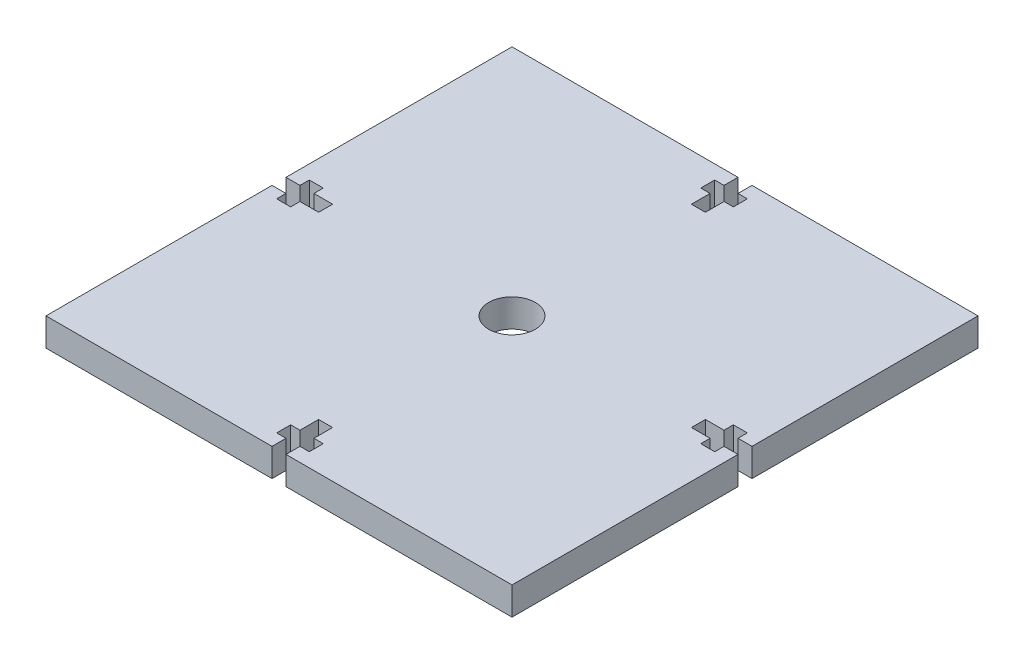
from build123d import *

# Parameters (mm, degrees)
SKETCH1_W           = 100
SKETCH1_H           = 100
BOSS_EXTRUDE1_DEPTH = 6
CUT_EXTRUDE1_DEPTH  = 142.548578234
SKETCH3_R           = 5
CUT_EXTRUDE2_DEPTH  = 10
CUT_EXTRUDE6_DEPTH  = 142.548578234


with BuildPart() as part:
    # Sketch1 → Boss-Extrude1 (new body)
    with BuildSketch(Plane(origin=(0, 0, 0), x_dir=(1, 0, 0), z_dir=(0, 1, 0))):
        with Locations((50, -50)):
            Rectangle(SKETCH1_W, SKETCH1_H)
    extrude(amount=BOSS_EXTRUDE1_DEPTH)

    # Sketch2 → Cut-Extrude1 (cut, through all)
    with BuildSketch(Plane(origin=(0, 6, 0), x_dir=(1, 0, 0), z_dir=(0, 1, 0))):
        Polygon((48.5, 0), (51.5, 0), (51.5, -3), (53.5, -3), (53.5, -6), (51.5, -6), (51.5, -10), (48.5, -10), (48.5, -6), (46.5, -6), (46.5, -3), (48.5, -3), align=None)
        Polygon((48.5, -100), (48.5, -97), (46.5, -97), (46.5, -94), (48.5, -94), (48.5, -90), (51.5, -90), (51.5, -94), (53.5, -94), (53.5, -97), (51.5, -97), (51.5, -100), align=None)
    extrude(amount=-CUT_EXTRUDE1_DEPTH, mode=Mode.SUBTRACT)

    # Sketch3 → Cut-Extrude2 (cut)
    with BuildSketch(Plane.XZ):
        with Locations(Location((50, 50, 0), (0, 0, 270))):
            Circle(SKETCH3_R)
    extrude(amount=-CUT_EXTRUDE2_DEPTH, mode=Mode.SUBTRACT)

    # Sketch5 → Cut-Extrude6 (cut, through all)
    with BuildSketch(Plane(origin=(0, 6, 0), x_dir=(1, 0, 0), z_dir=(0, 1, 0))):
        Polygon((3, -48.5), (0, -48.5), (0, -51.5), (3, -51.5), (3, -53.5), (6, -53.5), (6, -51.5), (10, -51.5), (10, -48.5), (6, -48.5), (6, -46.5), (3, -46.5), align=None)
        Polygon((90, -48.5), (90, -51.5), (94, -51.5), (94, -53.5), (97, -53.5), (97, -51.5), (100, -51.5), (100, -48.5), (97, -48.5), (97, -46.5), (94, -46.5), (94, -48.5), align=None)
    extrude(amount=-CUT_EXTRUDE6_DEPTH, mode=Mode.SUBTRACT)


solid = part.part
